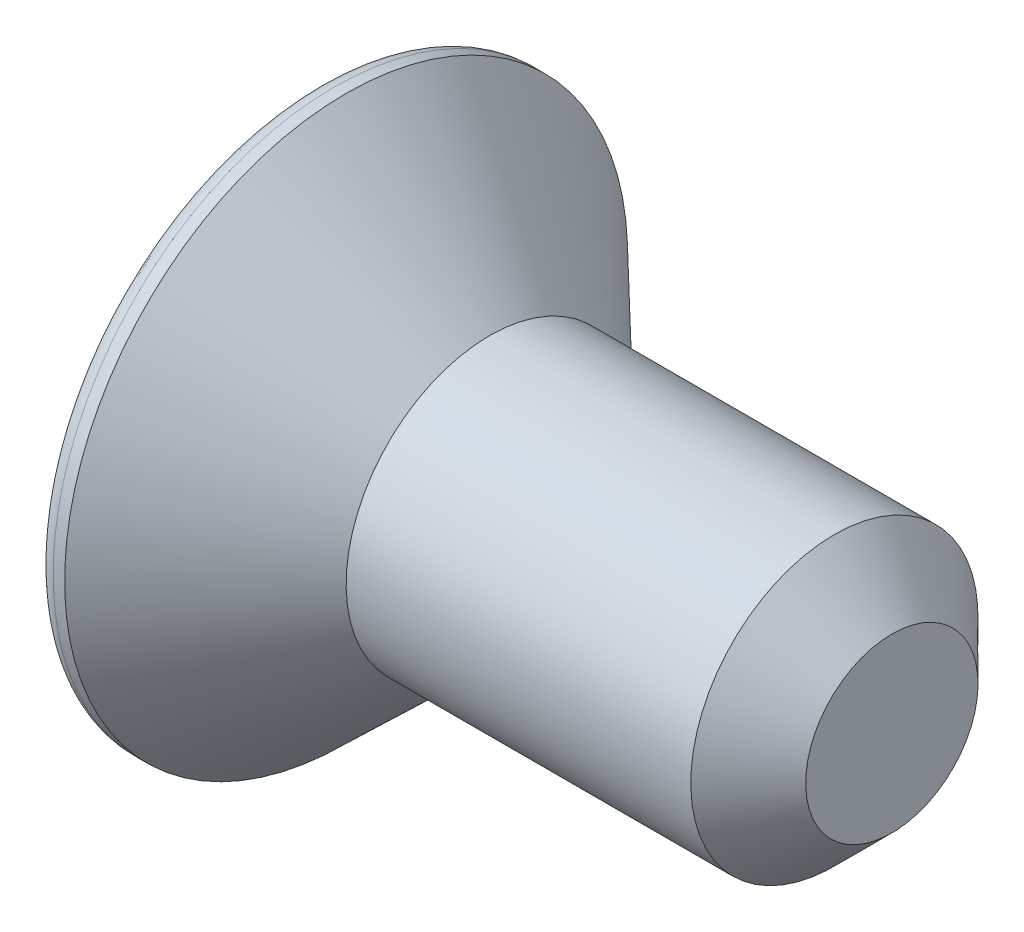
from build123d import *

# Parameters (mm, degrees)
CUT_EXTRUDE_1_DEPTH = 2
FILLET_1_R          = 0.3
CHAMFER_1_SIZE      = 1


with BuildPart() as part:
    # Эскиз1 → Повернуть1 (revolve)
    with BuildSketch(Plane.XY):
        Polygon((0, 0), (0, 4.9), (0.5, 4.9), (3, 2.5), (10, 2.5), (10, 0), align=None)
    revolve(axis=Axis((10, 0, 0), (-1, 0, 0)))

    # Эскиз2 → Вырез-Вытянуть1 (cut)
    with BuildSketch(Plane.ZY):
        Polygon((0.866025404, 1.5), (-0.866025404, 1.5), (-1.732050808, 0), (-0.866025404, -1.5), (0.866025404, -1.5), (1.732050808, 0), align=None)
    extrude(amount=-CUT_EXTRUDE_1_DEPTH, mode=Mode.SUBTRACT)

    # Скругление1
    fillet_1_edges = [part.edges().sort_by_distance(p)[0] for p in [
        (0, -4.9, 0),
    ]]
    fillet(fillet_1_edges, radius=FILLET_1_R)

    # Фаска1
    chamfer_1_edges = [part.edges().sort_by_distance(p)[0] for p in [
        (10, -2.5, 0),
    ]]
    chamfer(chamfer_1_edges, length=CHAMFER_1_SIZE)


solid = part.part
